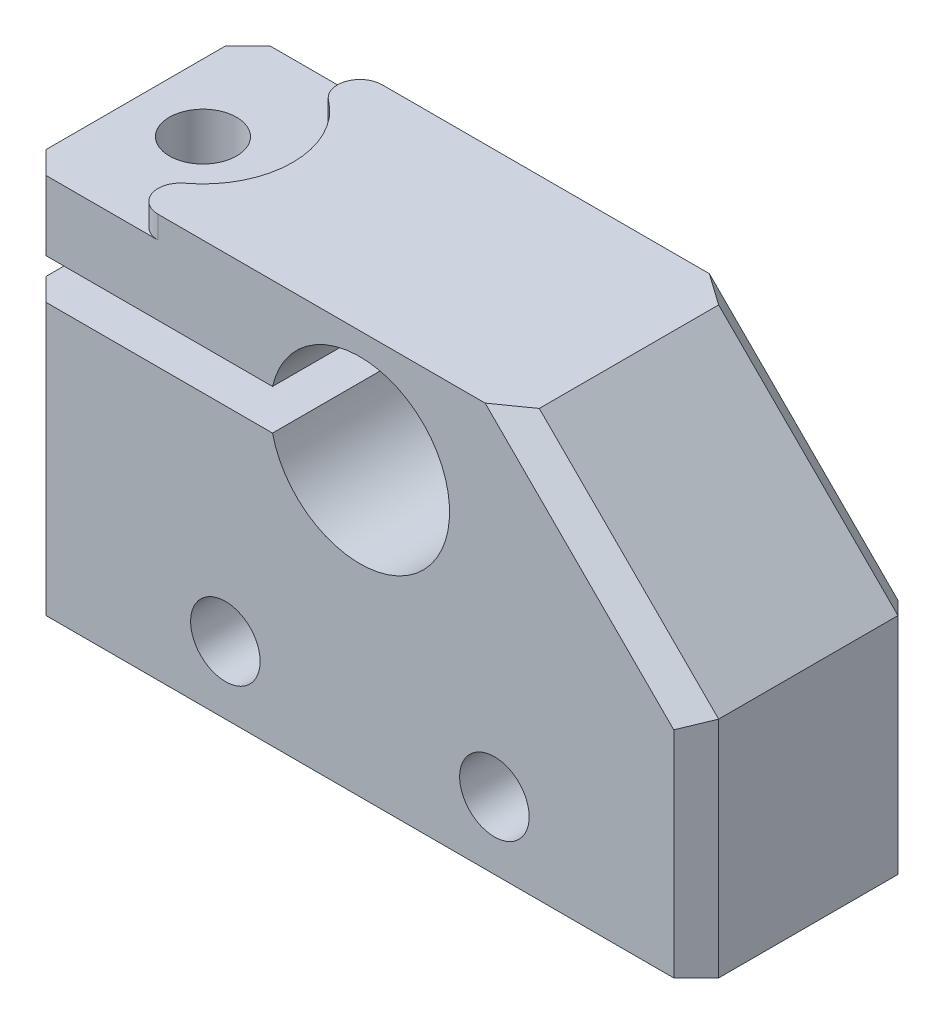
from build123d import *

# Parameters (mm, degrees)
SKETCH3_W                    = 30
SKETCH3_H                    = 8
SKETCH3_R                    = 1.55
BOSS_EXTRUDE1_DEPTH          = 5
SKETCH6_R                    = 4
BOSS_EXTRUDE2_DEPTH          = 10
SKETCH8_W                    = 15
SKETCH8_H                    = 1.8
CUT_EXTRUDE_THIN1_DEPTH      = 1
CUT_EXTRUDE_THIN1_DEPTH_BACK = 11
SKETCH9_R                    = 1.5
CUT_EXTRUDE1_DEPTH           = 19
CUT_EXTRUDE2_DEPTH           = 1
CHAMFER2_SIZE                = 1


with BuildPart() as part:
    # Sketch3 → Boss-Extrude1 (new body, symmetric)
    with BuildSketch(Plane.XY):
        Rectangle(SKETCH3_W, SKETCH3_H)
        with Locations((-6, -1)):
            Circle(SKETCH3_R, mode=Mode.SUBTRACT)
        with Locations((6, -1)):
            Circle(SKETCH3_R, mode=Mode.SUBTRACT)
    extrude(amount=BOSS_EXTRUDE1_DEPTH, both=True)

    # Sketch6 → Boss-Extrude2 (add)
    with BuildSketch(Plane.XY.offset(5)):
        Polygon((-15, 4), (15, 4), (15, 6), (7, 14), (-15, 14), align=None)
        with Locations((0, 9)):
            Circle(SKETCH6_R, mode=Mode.SUBTRACT)
    extrude(amount=-BOSS_EXTRUDE2_DEPTH)

    # Sketch8 → Cut-Extrude-Thin1 (cut, two sides)
    with BuildSketch(Plane.XY.offset(5)) as cut_extrude_thin1_sk:
        with Locations((-7.5, 9)):
            Rectangle(SKETCH8_W, SKETCH8_H)
    extrude(amount=CUT_EXTRUDE_THIN1_DEPTH, mode=Mode.SUBTRACT)
    extrude(cut_extrude_thin1_sk.sketch, amount=-CUT_EXTRUDE_THIN1_DEPTH_BACK, mode=Mode.SUBTRACT)

    # Sketch9 → Cut-Extrude1 (cut, through all)
    with BuildSketch(Plane(origin=(0, 14, 0), x_dir=(1, 0, 0), z_dir=(0, 1, 0))):
        with Locations((-12, 0)):
            Circle(SKETCH9_R)
    extrude(amount=-CUT_EXTRUDE1_DEPTH, mode=Mode.SUBTRACT)

    # Sketch10 → Cut-Extrude2 (cut)
    with BuildSketch(Plane(origin=(0, 14, 0), x_dir=(1, 0, 0), z_dir=(0, 1, 0))):
        with BuildLine():
            Line((-9, 5), (-15, 5))
            Line((-15, 5), (-15, -5))
            Line((-15, -5), (-9, -5))
            ThreePointArc((-9, -5), (-9.948683298, -4.316227766), (-9.6, -3.2))
            ThreePointArc((-9.6, -3.2), (-8, 0), (-9.6, 3.2))
            ThreePointArc((-9.6, 3.2), (-9.948683298, 4.316227766), (-9, 5))
        make_face()
    extrude(amount=-CUT_EXTRUDE2_DEPTH, mode=Mode.SUBTRACT)

    # Chamfer2
    chamfer2_edges = [part.edges().sort_by_distance(p)[0] for p in [
        (11, 10, -5),
        (11, 10, 5),
        (-15, 2.05, -5),
        (-15, 2.05, 5),
        (15, 1, 5),
        (15, 1, -5),
        (-15, 11.45, -5),
        (-15, 11.45, 5),
    ]]
    chamfer(chamfer2_edges, length=CHAMFER2_SIZE)


solid = part.part
